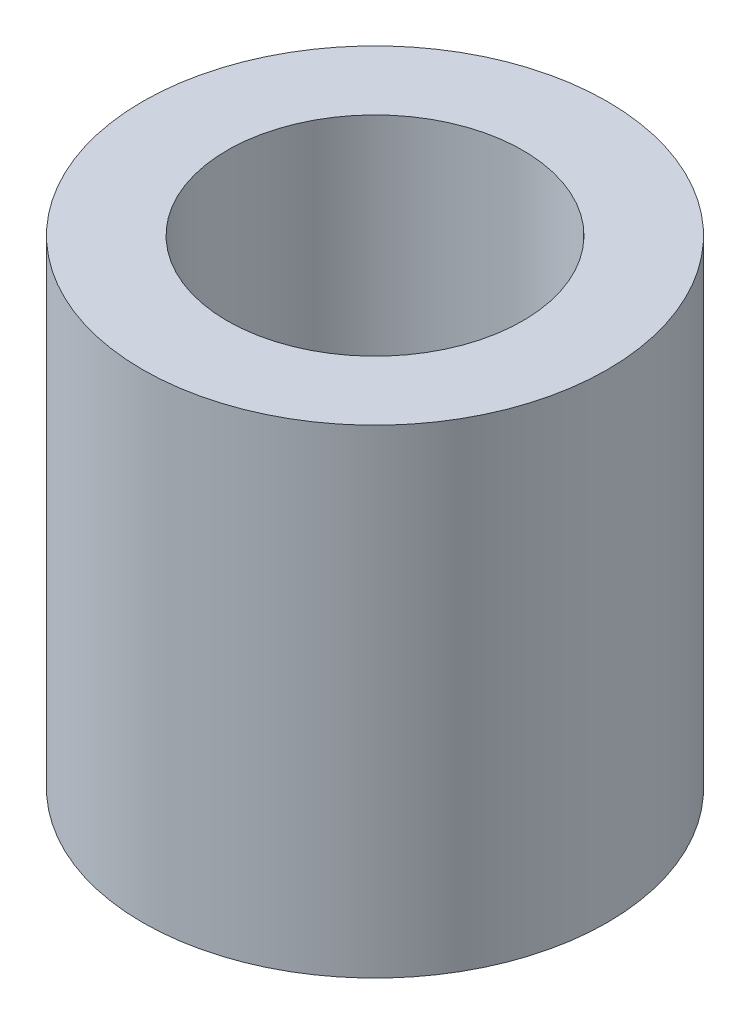
from build123d import *

# Parameters (mm, degrees)
SKETCH1_R           = 4.9911
SKETCH1_R_2         = 3.175
BOSS_EXTRUDE1_DEPTH = 10.287


with BuildPart() as part:
    # Sketch1 → Boss-Extrude1 (new body)
    with BuildSketch(Plane(origin=(0, 0, 0), x_dir=(1, 0, 0), z_dir=(0, 1, 0))):
        Circle(SKETCH1_R)
        Circle(SKETCH1_R_2, mode=Mode.SUBTRACT)
    extrude(amount=BOSS_EXTRUDE1_DEPTH)


solid = part.part
